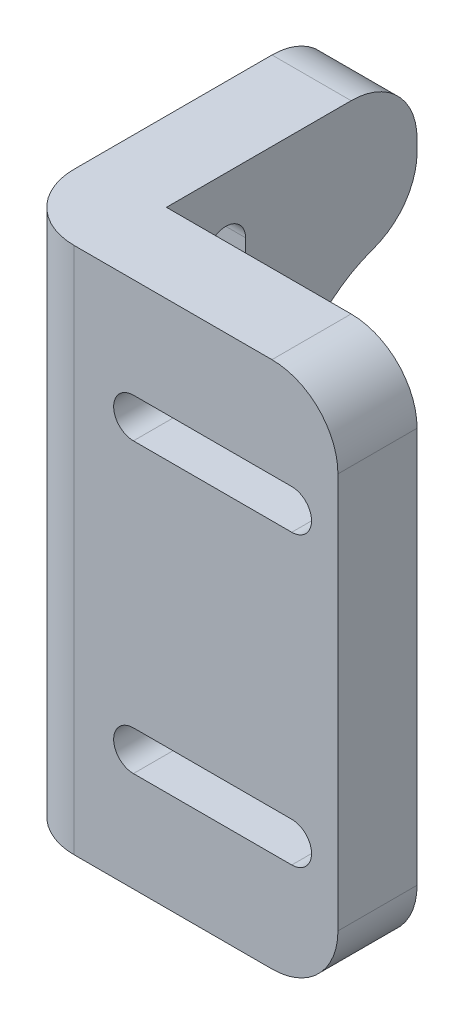
from build123d import *

# Parameters (mm, degrees)
SKETCH1_W           = 6
SKETCH1_H           = 19
SKETCH1_H_2         = 6
SKETCH1_W_2         = 19
BOSS_EXTRUDE1_DEPTH = 40
CUT_EXTRUDE1_REACH  = 8
SKETCH2_R           = 10
CUT_EXTRUDE2_REACH  = 27
CUT_EXTRUDE3_DEPTH  = 3
FILLET1_R           = 5


with BuildPart() as part:
    # Sketch1 → Boss-Extrude1 (new body)
    with BuildSketch(Plane(origin=(0, 0, 0), x_dir=(1, 0, 0), z_dir=(0, 1, 0))):
        with Locations((-9.5, 12.5)):
            Rectangle(SKETCH1_W, SKETCH1_H)
        with Locations((-9.5, 0)):
            Rectangle(SKETCH1_W, SKETCH1_H_2)
        with Locations((3, 0)):
            Rectangle(SKETCH1_W_2, SKETCH1_H_2)
    extrude(amount=BOSS_EXTRUDE1_DEPTH)

    # Sketch2 → Cut-Extrude1 (cut, up to next)
    with BuildSketch(Plane(origin=(-6.5, 0, 0), x_dir=(0, 0, -1), z_dir=(1, 0, 0)), mode=Mode.PRIVATE) as cut_extrude1_sk1:
        with Locations((22, 20)):
            Circle(SKETCH2_R)
    cut_extrude1_tool1 = extrude(cut_extrude1_sk1.sketch, amount=-CUT_EXTRUDE1_REACH, mode=Mode.PRIVATE) & part.part
    add(cut_extrude1_tool1.solids().sort_by_distance((-6.5, 20, -22))[0], mode=Mode.SUBTRACT)
    # Sketch2 → Cut-Extrude1 (cut, up to next)
    with BuildSketch(Plane(origin=(-6.5, 0, 0), x_dir=(0, 0, -1), z_dir=(1, 0, 0)), mode=Mode.PRIVATE) as cut_extrude1_sk2:
        with BuildLine():
            Line((9, 35), (9, 25))
            ThreePointArc((9, 25), (7.5, 23.5), (6, 25))
            Line((6, 25), (6, 35))
            ThreePointArc((6, 35), (7.5, 36.5), (9, 35))
        make_face()
    cut_extrude1_tool2 = extrude(cut_extrude1_sk2.sketch, amount=-CUT_EXTRUDE1_REACH, mode=Mode.PRIVATE) & part.part
    add(cut_extrude1_tool2.solids().sort_by_distance((-6.5, 30, -7.5))[0], mode=Mode.SUBTRACT)
    # Sketch2 → Cut-Extrude1 (cut, up to next)
    with BuildSketch(Plane(origin=(-6.5, 0, 0), x_dir=(0, 0, -1), z_dir=(1, 0, 0)), mode=Mode.PRIVATE) as cut_extrude1_sk3:
        with BuildLine():
            Line((9, 5), (9, 15))
            ThreePointArc((9, 15), (7.5, 16.5), (6, 15))
            Line((6, 15), (6, 5))
            ThreePointArc((6, 5), (7.5, 3.5), (9, 5))
        make_face()
    cut_extrude1_tool3 = extrude(cut_extrude1_sk3.sketch, amount=-CUT_EXTRUDE1_REACH, mode=Mode.PRIVATE) & part.part
    add(cut_extrude1_tool3.solids().sort_by_distance((-6.5, 10, -7.5))[0], mode=Mode.SUBTRACT)

    # Sketch3 → Cut-Extrude2 (cut, up to next)
    with BuildSketch(Plane(origin=(0, 0, 3), x_dir=(-1, 0, 0), z_dir=(0, 0, -1)), mode=Mode.PRIVATE) as cut_extrude2_sk1:
        with BuildLine():
            Line((-9, 32.42), (3, 32.42))
            ThreePointArc((3, 32.42), (4.5, 30.92), (3, 29.42))
            Line((3, 29.42), (-9, 29.42))
            ThreePointArc((-9, 29.42), (-10.5, 30.92), (-9, 32.42))
        make_face()
    cut_extrude2_tool1 = extrude(cut_extrude2_sk1.sketch, amount=CUT_EXTRUDE2_REACH, mode=Mode.PRIVATE) & part.part
    add(cut_extrude2_tool1.solids().sort_by_distance((3, 30.92, 3))[0], mode=Mode.SUBTRACT)
    # Sketch3 → Cut-Extrude2 (cut, up to next)
    with BuildSketch(Plane(origin=(0, 0, 3), x_dir=(-1, 0, 0), z_dir=(0, 0, -1)), mode=Mode.PRIVATE) as cut_extrude2_sk2:
        with BuildLine():
            Line((-9, 10.58), (3, 10.58))
            ThreePointArc((3, 10.58), (4.5, 9.08), (3, 7.58))
            Line((3, 7.58), (-9, 7.58))
            ThreePointArc((-9, 7.58), (-10.5, 9.08), (-9, 10.58))
        make_face()
    cut_extrude2_tool2 = extrude(cut_extrude2_sk2.sketch, amount=CUT_EXTRUDE2_REACH, mode=Mode.PRIVATE) & part.part
    add(cut_extrude2_tool2.solids().sort_by_distance((3, 9.08, 3))[0], mode=Mode.SUBTRACT)

    # Sketch4 → Cut-Extrude3 (cut)
    with BuildSketch(Plane(origin=(0, 0, -3), x_dir=(-1, 0, 0), z_dir=(0, 0, -1))):
        with BuildLine():
            Line((-9, 6.33), (3, 6.33))
            ThreePointArc((3, 6.33), (5.75, 9.08), (3, 11.83))
            Line((3, 11.83), (-9, 11.83))
            ThreePointArc((-9, 11.83), (-11.75, 9.08), (-9, 6.33))
        make_face()
        with BuildLine():
            Line((-9, 33.67), (3, 33.67))
            ThreePointArc((3, 33.67), (5.75, 30.92), (3, 28.17))
            Line((3, 28.17), (-9, 28.17))
            ThreePointArc((-9, 28.17), (-11.75, 30.92), (-9, 33.67))
        make_face()
    extrude(amount=-CUT_EXTRUDE3_DEPTH, mode=Mode.SUBTRACT)

    # Fillet1
    fillet1_edges = [part.edges().sort_by_distance(p)[0] for p in [
        (-12.5, 20, 3),
        (12.5, 40, 0),
        (-9.5, 40, -22),
        (-9.5, 30, -22),
        (-9.5, 10, -22),
        (-9.5, 0, -22),
        (12.5, 0, 0),
    ]]
    fillet(fillet1_edges, radius=FILLET1_R)


solid = part.part
